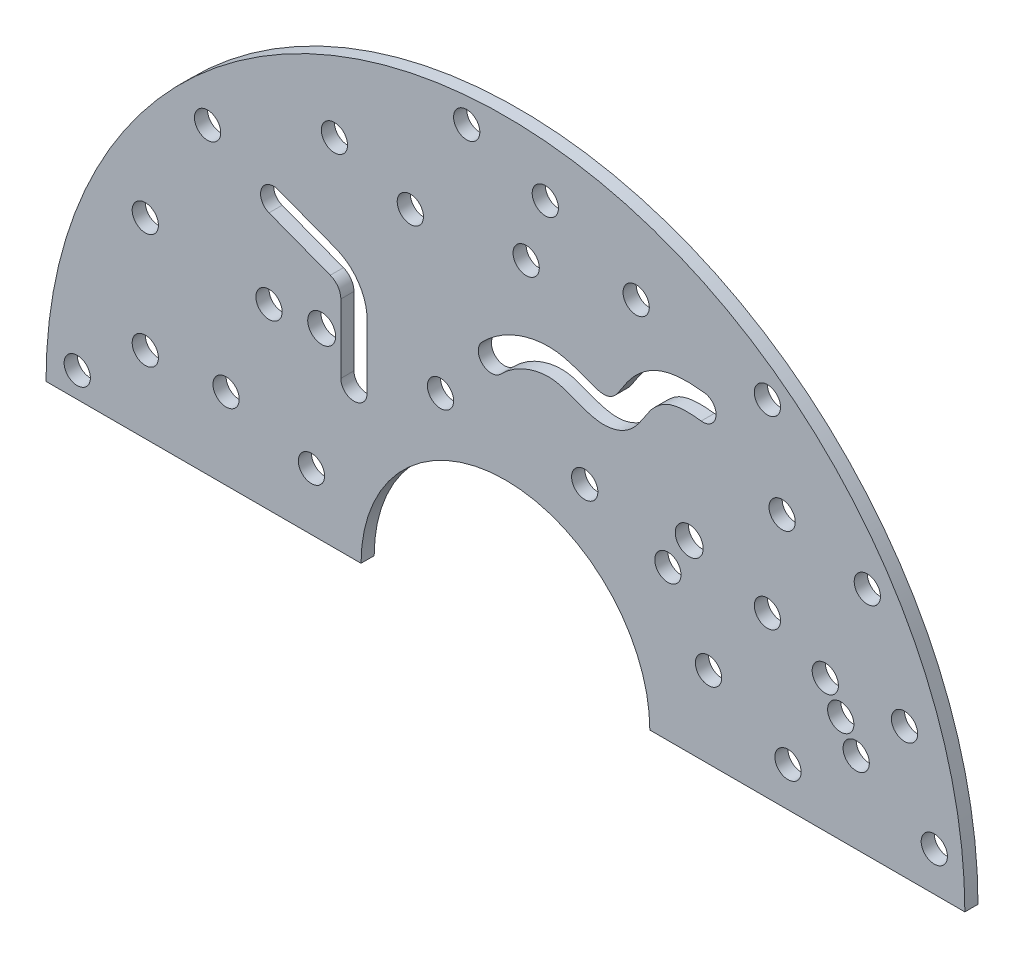
from build123d import *

# Parameters (mm, degrees)
AUFSATZ_LINEAR_AUSTRAGEN1_DEPTH = 4
AUFSATZ_LINEAR_START            = -4
AUFSATZ_LINEAR_AUSTRAGEN2_DEPTH = 4
SKIZZE3_R                       = 4
SCHNITT_LINEAR_AUSTRAGEN1_DEPTH = 5
KREISMUSTER1_COUNT              = 2
KREISMUSTER1_ANGLE              = 180
SKIZZE4_R                       = 4.25
SCHNITT_LINEAR_AUSTRAGEN2_DEPTH = 5.0000001
SCHNITT_LINEAR_AUSTRAGEN6_DEPTH = 5.0000001


with BuildPart() as part:
    # Skizze1 → Aufsatz-Linear austragen1 (new body)
    with BuildSketch(Plane.XY):
        with BuildLine():
            Line((-140, 0), (-44, 0))
            ThreePointArc((-44, 0), (0, 44), (44, 0))
            Line((44, 0), (140, 0))
            ThreePointArc((140, 0), (0, 140), (-140, 0))
        make_face()
    extrude(amount=AUFSATZ_LINEAR_AUSTRAGEN1_DEPTH)

    # Skizze3 → Schnitt-Linear austragen1 (cut, through all)
    with BuildSketch(Plane.XY.offset(4)):
        with Locations((97.465855695, 40.443417178)):
            Circle(SKIZZE3_R)
        with Locations((-28.978013808, 100.95566101)):
            Circle(SKIZZE3_R)
        with Locations((-85.117795529, 24.678050469)):
            Circle(SKIZZE3_R)
        with Locations((49.499676508, 45.715671604)):
            Circle(SKIZZE3_R)
        with Locations((84.316672436, 77.025430252)):
            Circle(SKIZZE3_R)
        with Locations((-109.742542616, 58.329937472)):
            Circle(SKIZZE3_R)
        with Locations((12.152070307, 123.764162201)):
            Circle(SKIZZE3_R)
        with Locations((61.8820811, 24.678050469)):
            Circle(SKIZZE3_R)
        with Locations((130.681494529, 11.965115379)):
            Circle(SKIZZE3_R)
        with Locations((-19.788462476, 56.975749593)):
            Circle(SKIZZE3_R)
        with Locations((24.156878396, 54.91258805)):
            Circle(SKIZZE3_R)
        with Locations((39.836906124, 111.443214335)):
            Circle(SKIZZE3_R)
        with Locations((-59.111041928, 17.478585009)):
            Circle(SKIZZE3_R)
        with Locations((-72.048480667, 54.3235981)):
            Circle(SKIZZE3_R)
        with Locations((-109.742542616, 23.34359544)):
            Circle(SKIZZE3_R)
        with Locations((-52.111041928, 108.293664898)):
            Circle(SKIZZE3_R)
        with Locations((-11.804027303, 131.860260966)):
            Circle(SKIZZE3_R)
        with Locations((6.318783693, 105.077612676)):
            Circle(SKIZZE3_R)
        with Locations((110.273697847, 70.350224162)):
            Circle(SKIZZE3_R)
        with Locations((121.607291156, 39.801130304)):
            Circle(SKIZZE3_R)
        with Locations((86.095365454, 11.965115379)):
            Circle(SKIZZE3_R)
        with Locations((79.830146969, 48.78022616)):
            Circle(SKIZZE3_R)
        with Locations((102.175417409, 32.560733823)):
            Circle(SKIZZE3_R)
        with Locations((106.884979123, 24.678050469)):
            Circle(SKIZZE3_R)
        with Locations((79.830146969, 105.077612676)):
            Circle(SKIZZE3_R)
        with Locations((-90.76433729, 92.248559489)):
            Circle(SKIZZE3_R)
        with Locations((-130.481598714, 7.661365172)):
            Circle(SKIZZE3_R)
        with BuildLine():
            Line((-69.194164222, 85.93909128), (-51.809779549, 79.29954097))
            ThreePointArc((-51.809779549, 79.29954097), (-44.806914265, 73.793306383), (-42.161622882, 65.286769191))
            Line((-42.161622882, 65.286769191), (-42.161622882, 45.715671604))
            ThreePointArc((-42.161622882, 45.715671604), (-46.161622882, 41.715671604), (-50.161622882, 45.715671604))
            Line((-50.161622882, 45.715671604), (-50.161622882, 66.663821043))
            ThreePointArc((-50.161622882, 66.663821043), (-51.043386676, 69.49933344), (-53.377675104, 71.334744969))
            Line((-53.377675104, 71.334744969), (-72.048480667, 78.465612998))
            ThreePointArc((-72.048480667, 78.465612998), (-74.358061586, 83.629510361), (-69.194164222, 85.93909128))
        make_face()
        with BuildLine():
            ThreePointArc((59.646721968, 89.376202207), (64.147568268, 92.802918212), (60.720852262, 97.303764512))
            add(Edge.make_bspline(
                [(60.720852262, 97.303764512), (50.253024592, 98.722083333), (36.618963976, 91.501822661), (35.049635356, 83.116773386), (28.228487587, 80.493067875), (15.98996772, 89.015739936), (-0.4259756, 83.722263265), (-7.147981409, 76.803997307)],
                knots=[0, 0, 0, 0, 0.155350823, 0.402837105, 0.456860775, 0.695587526, 1, 1, 1, 1], degree=3))
            ThreePointArc((-7.147981409, 76.803997307), (-7.066597389, 71.147728516), (-1.410328598, 71.229112536))
            add(Edge.make_bspline(
                [(59.646721968, 89.376202207), (59.224039082, 89.433472838), (58.353128752, 89.536713479), (56.794265381, 89.665179204), (55.049191603, 89.709444401), (53.295805349, 89.610418971), (51.350048397, 89.327625906), (49.553580127, 88.781707234), (48.238388062, 88.100988422), (47.288957061, 87.461682497), (46.575191923, 86.905201551), (45.910324977, 86.326903878), (45.141740672, 85.583449289), (44.329258338, 84.667037187), (43.206221079, 83.166913867), (42.174814317, 81.476884138), (40.728491779, 79.298762186), (39.175673345, 77.37956056), (36.766411609, 75.351719758), (34.090689098, 74.121665999), (31.677828193, 73.617951831), (29.228396224, 73.49496001), (26.762610597, 73.869098039), (24.364756292, 74.566730405), (22.290249105, 75.333408471), (20.396377608, 76.077690047), (18.632159097, 76.738262311), (16.984680069, 77.264150095), (15.480487252, 77.6158041), (14.076862312, 77.787177643), (12.480590355, 77.808891855), (10.791598978, 77.653734637), (8.43462818, 77.20140029), (5.386558712, 76.158816504), (2.401197885, 74.469544973), (0.16281186, 72.746720517), (-0.905945733, 71.748221698), (-1.410328598, 71.229112536)],
                knots=[0, 0, 0, 0, 0.0078125, 0.015625, 0.03125, 0.046875, 0.0625, 0.09375, 0.125, 0.140625, 0.15625, 0.171875, 0.1875, 0.21875, 0.25, 0.3125, 0.34375, 0.375, 0.40625, 0.4375, 0.453125, 0.46875, 0.5, 0.53125, 0.5625, 0.59375, 0.625, 0.65625, 0.6875, 0.71875, 0.75, 0.78125, 0.8125, 0.875, 0.9375, 0.96875, 1, 1, 1, 1], degree=3))
        make_face()
    schnitt_linear_austragen1 = extrude(amount=-SCHNITT_LINEAR_AUSTRAGEN1_DEPTH, mode=Mode.SUBTRACT)


with BuildPart() as body_2:
    # Skizze2 → Aufsatz-Linear austragen2 (new body)
    with BuildSketch(Plane.XY.offset(4).offset(AUFSATZ_LINEAR_START)):
        with BuildLine():
            Line((140, 0), (44, 0))
            ThreePointArc((44, 0), (0, -44), (-44, 0))
            Line((-44, 0), (-140, 0))
            ThreePointArc((-140, 0), (0, -140), (140, 0))
        make_face()
    extrude(amount=AUFSATZ_LINEAR_AUSTRAGEN2_DEPTH)

    # Kreismuster1: Schnitt-Linear austragen1 ×2 about axis
    kreismuster1_axis = Axis((0, 0, 4), (0, 0, -1))
    for i in range(1, KREISMUSTER1_COUNT):
        add(schnitt_linear_austragen1.rotate(kreismuster1_axis, i * KREISMUSTER1_ANGLE / (KREISMUSTER1_COUNT - 1)), mode=Mode.SUBTRACT)


with BuildPart() as schnitt_linear_austragen2_tool:
    # Skizze4 → Schnitt-Linear austragen2 (new body, through all)
    with BuildSketch(Plane.XY.offset(4)):
        with Locations((56, 56)):
            Circle(SKIZZE4_R)
        with Locations((-56, 56)):
            Circle(SKIZZE4_R)
        with Locations((-56, -56)):
            Circle(SKIZZE4_R)
        with Locations((56, -56)):
            Circle(SKIZZE4_R)
    extrude(amount=-SCHNITT_LINEAR_AUSTRAGEN2_DEPTH)


with BuildPart() as part_1:
    add(part.part)

    # Schnitt-Linear austragen2: cut by schnitt_linear_austragen2_tool
    add(schnitt_linear_austragen2_tool.part, mode=Mode.SUBTRACT)


with BuildPart() as body_2_1:
    add(body_2.part)

    # Schnitt-Linear austragen2: cut by schnitt_linear_austragen2_tool
    add(schnitt_linear_austragen2_tool.part, mode=Mode.SUBTRACT)

    # Skizze9 → Schnitt-Linear austragen6 (cut, through all)
    with BuildSketch(Plane(origin=(0, 0, 0), x_dir=(-1, 0, 0), z_dir=(0, 0, -1))):
        with BuildLine():
            Line((-44, 0), (-140, 0))
            ThreePointArc((-140, 0), (0, -140), (140, 0))
            Line((140, 0), (44, 0))
            ThreePointArc((44, 0), (0, -44), (-44, 0))
        make_face()
    extrude(amount=-SCHNITT_LINEAR_AUSTRAGEN6_DEPTH, mode=Mode.SUBTRACT)


solid = part_1.part
